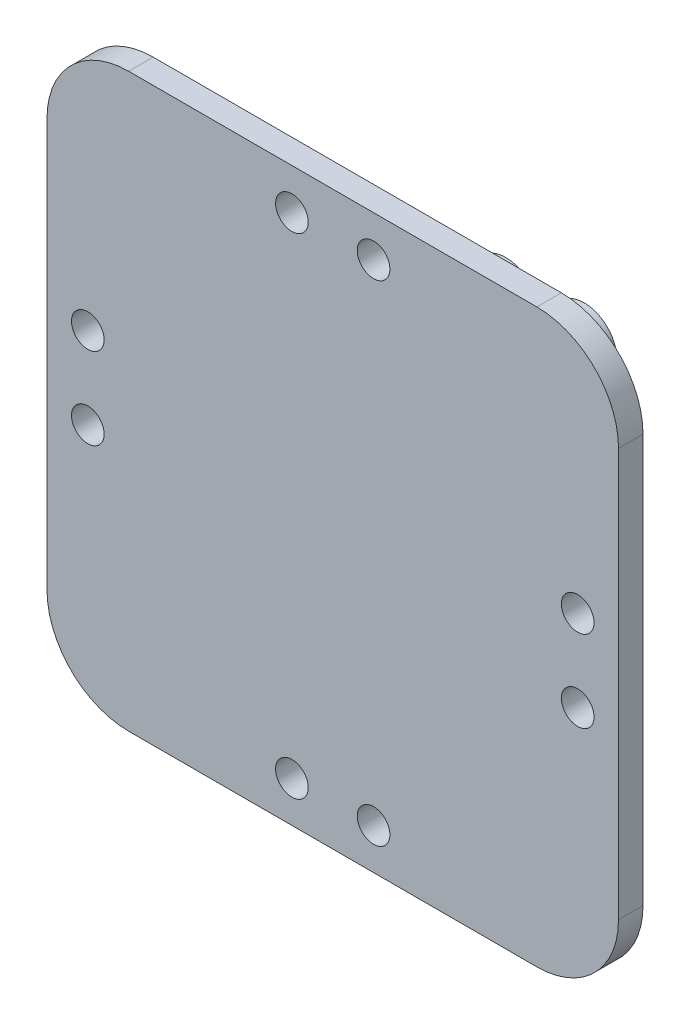
from build123d import *

# Parameters (mm, degrees)
SKETCH_1_R           = 1.75
EXTRUDE_3_DEPTH      = 3
EXTRUDE_4_DEPTH      = 15
SKETCH_3_R           = 1
CUT_EXTRUDE_5_DEPTH  = 7.5
SKETCH_8_R           = 0.85
CUT_EXTRUDE_8_DEPTH  = 9
SKETCH_10_R          = 0.85
CUT_EXTRUDE_9_DEPTH  = 9
SKETCH_11_R          = 0.85
CUT_EXTRUDE_10_DEPTH = 9
SKETCH_12_R          = 0.85
CUT_EXTRUDE_11_DEPTH = 9
SKETCH_13_R          = 2
SKETCH_13_R_2        = 0.85
EXTRUDE_5_DEPTH      = 10
SKETCH_14_R          = 2
SKETCH_14_R_2        = 0.85
EXTRUDE_6_DEPTH      = 10
SKETCH_15_R          = 2
SKETCH_15_R_2        = 0.85
EXTRUDE_7_DEPTH      = 10
SKETCH_16_R          = 2
SKETCH_16_R_2        = 0.85
EXTRUDE_8_DEPTH      = 10
SKETCH_17_R          = 4
SKETCH_17_R_2        = 2
EXTRUDE_9_DEPTH      = 8
SKETCH_18_R          = 1.75
EXTRUDE_10_DEPTH     = 3
SKETCH_19_R          = 2
EXTRUDE_11_DEPTH     = 3


with BuildPart() as part:
    # 草图1 → 凸台-拉伸3 (new body)
    with BuildSketch(Plane.XY):
        with BuildLine():
            Line((-18, -25), (18, -25))
            ThreePointArc((18, -25), (22.949747468, -22.949747468), (25, -18))
            Line((25, -18), (25, 18))
            ThreePointArc((25, 18), (22.949747468, 22.949747468), (18, 25))
            Line((18, 25), (-18, 25))
            ThreePointArc((-18, 25), (-22.949747468, 22.949747468), (-25, 18))
            Line((-25, 18), (-25, -18))
            ThreePointArc((-25, -18), (-22.949747468, -22.949747468), (-18, -25))
        make_face()
        with Locations((20, 20)):
            Circle(SKETCH_1_R, mode=Mode.SUBTRACT)
        with Locations((-20, 20)):
            Circle(SKETCH_1_R, mode=Mode.SUBTRACT)
        with Locations((-20, -20)):
            Circle(SKETCH_1_R, mode=Mode.SUBTRACT)
        with Locations((20, -20)):
            Circle(SKETCH_1_R, mode=Mode.SUBTRACT)
    extrude(amount=EXTRUDE_3_DEPTH)

    # 草图2 → 凸台-拉伸4 (add)
    with BuildSketch(Plane(origin=(0, 0, 0), x_dir=(-1, 0, 0), z_dir=(0, 0, -1))):
        Polygon((9.814954576, -17), (19.629909152, 0), (9.814954576, 17), (-9.814954576, 17), (-19.629909152, 0), (-9.814954576, -17), align=None)
    extrude(amount=EXTRUDE_4_DEPTH)

    # 草图3 → 切除-拉伸5 (cut)
    with BuildSketch(Plane(origin=(0, 0, -15), x_dir=(-1, 0, 0), z_dir=(0, 0, -1))):
        with Locations((-4.815101245, 8.34)):
            Circle(SKETCH_3_R)
        with Locations((4.815101245, 8.34)):
            Circle(SKETCH_3_R)
        with Locations((4.815101245, -8.34)):
            Circle(SKETCH_3_R)
        with Locations((-4.815101245, -8.34)):
            Circle(SKETCH_3_R)
    extrude(amount=-CUT_EXTRUDE_5_DEPTH, mode=Mode.SUBTRACT)

    # 草图8 → 切除-拉伸8 (cut)
    with BuildSketch(Plane(origin=(14.722431864, 8.5, 0), x_dir=(0, 0, -1), z_dir=(0.866025404, 0.5, 0))):
        with Locations((10, 4.814954576)):
            Circle(SKETCH_8_R)
    extrude(amount=-CUT_EXTRUDE_8_DEPTH, mode=Mode.SUBTRACT)

    # 草图10 → 切除-拉伸9 (cut)
    with BuildSketch(Plane(origin=(-14.722431864, 8.5, 0), x_dir=(0, 0, 1), z_dir=(-0.866025404, 0.5, 0))):
        with Locations((-10, 4.814954576)):
            Circle(SKETCH_10_R)
    extrude(amount=-CUT_EXTRUDE_9_DEPTH, mode=Mode.SUBTRACT)

    # 草图11 → 切除-拉伸10 (cut)
    with BuildSketch(Plane(origin=(-14.722431864, -8.5, 0), x_dir=(0, 0, 1), z_dir=(-0.866025404, -0.5, 0))):
        with Locations((-10, -4.814954576)):
            Circle(SKETCH_11_R)
    extrude(amount=-CUT_EXTRUDE_10_DEPTH, mode=Mode.SUBTRACT)

    # 草图12 → 切除-拉伸11 (cut)
    with BuildSketch(Plane(origin=(14.722431864, -8.5, 0), x_dir=(0, 0, -1), z_dir=(0.866025404, -0.5, 0))):
        with Locations((10, -4.814954576)):
            Circle(SKETCH_12_R)
    extrude(amount=-CUT_EXTRUDE_11_DEPTH, mode=Mode.SUBTRACT)

    # 草图13 → 凸台-拉伸5 (add)
    with BuildSketch(Plane(origin=(14.722431864, 8.5, 0), x_dir=(0, 0, -1), z_dir=(0.866025404, 0.5, 0))):
        with Locations((10, 4.814954576)):
            Circle(SKETCH_13_R)
        with Locations((10, 4.814954576)):
            Circle(SKETCH_13_R_2, mode=Mode.SUBTRACT)
    extrude(amount=EXTRUDE_5_DEPTH)

    # 草图14 → 凸台-拉伸6 (add)
    with BuildSketch(Plane(origin=(-14.722431864, 8.5, 0), x_dir=(0, 0, 1), z_dir=(-0.866025404, 0.5, 0))):
        with Locations((-10, 4.814954576)):
            Circle(SKETCH_14_R)
        with Locations((-10, 4.814954576)):
            Circle(SKETCH_14_R_2, mode=Mode.SUBTRACT)
    extrude(amount=EXTRUDE_6_DEPTH)

    # 草图15 → 凸台-拉伸7 (add)
    with BuildSketch(Plane(origin=(-14.722431864, -8.5, 0), x_dir=(0, 0, 1), z_dir=(-0.866025404, -0.5, 0))):
        with Locations((-10, -4.814954576)):
            Circle(SKETCH_15_R)
        with Locations((-10, -4.814954576)):
            Circle(SKETCH_15_R_2, mode=Mode.SUBTRACT)
    extrude(amount=EXTRUDE_7_DEPTH)

    # 草图16 → 凸台-拉伸8 (add)
    with BuildSketch(Plane(origin=(14.722431864, -8.5, 0), x_dir=(0, 0, -1), z_dir=(0.866025404, -0.5, 0))):
        with Locations((10, -4.814954576)):
            Circle(SKETCH_16_R)
        with Locations((10, -4.814954576)):
            Circle(SKETCH_16_R_2, mode=Mode.SUBTRACT)
    extrude(amount=EXTRUDE_8_DEPTH)

    # 草图17 → 凸台-拉伸9 (add)
    with BuildSketch(Plane(origin=(0, 0, -15), x_dir=(-1, 0, 0), z_dir=(0, 0, -1))):
        with Locations((4.815101245, 8.34)):
            Circle(SKETCH_17_R)
        with Locations((4.815101245, 8.34)):
            Circle(SKETCH_17_R_2, mode=Mode.SUBTRACT)
        with Locations((-4.815101245, 8.34)):
            Circle(SKETCH_17_R)
        with Locations((-4.815101245, 8.34)):
            Circle(SKETCH_17_R_2, mode=Mode.SUBTRACT)
        with Locations((-4.815101245, -8.34)):
            Circle(SKETCH_17_R)
        with Locations((-4.815101245, -8.34)):
            Circle(SKETCH_17_R_2, mode=Mode.SUBTRACT)
        with Locations((4.815101245, -8.34)):
            Circle(SKETCH_17_R)
        with Locations((4.815101245, -8.34)):
            Circle(SKETCH_17_R_2, mode=Mode.SUBTRACT)
    extrude(amount=EXTRUDE_9_DEPTH)

    # 草图18 → 凸台-拉伸10 (add)
    with BuildSketch(Plane(origin=(0, 0, 0), x_dir=(-1, 0, 0), z_dir=(0, 0, -1))):
        with Locations((20, 20)):
            Circle(SKETCH_18_R)
        with Locations((-20, 20)):
            Circle(SKETCH_18_R)
        with Locations((-20, -20)):
            Circle(SKETCH_18_R)
        with Locations((20, -20)):
            Circle(SKETCH_18_R)
    extrude(amount=-EXTRUDE_10_DEPTH)

    # 草图19 → 凸台-拉伸11 (add)
    with BuildSketch(Plane(origin=(0, 0, 0), x_dir=(-1, 0, 0), z_dir=(0, 0, -1))):
        with BuildLine():
            Line((-25, 35), (25, 35))
            ThreePointArc((25, 35), (32.071067812, 32.071067812), (35, 25))
            Line((35, 25), (35, -25))
            ThreePointArc((35, -25), (32.071067812, -32.071067812), (25, -35))
            Line((25, -35), (-25, -35))
            ThreePointArc((-25, -35), (-32.071067812, -32.071067812), (-35, -25))
            Line((-35, -25), (-35, 25))
            ThreePointArc((-35, 25), (-32.071067812, 32.071067812), (-25, 35))
        make_face()
        with Locations((-30, 5)):
            Circle(SKETCH_19_R, mode=Mode.SUBTRACT)
        with Locations((-30, -5)):
            Circle(SKETCH_19_R, mode=Mode.SUBTRACT)
        with Locations((-5, -30)):
            Circle(SKETCH_19_R, mode=Mode.SUBTRACT)
        with Locations((5, -30)):
            Circle(SKETCH_19_R, mode=Mode.SUBTRACT)
        with Locations((-5, 30)):
            Circle(SKETCH_19_R, mode=Mode.SUBTRACT)
        with Locations((5, 30)):
            Circle(SKETCH_19_R, mode=Mode.SUBTRACT)
        with Locations((30, 5)):
            Circle(SKETCH_19_R, mode=Mode.SUBTRACT)
        with Locations((30, -5)):
            Circle(SKETCH_19_R, mode=Mode.SUBTRACT)
    extrude(amount=-EXTRUDE_11_DEPTH)


solid = part.part
